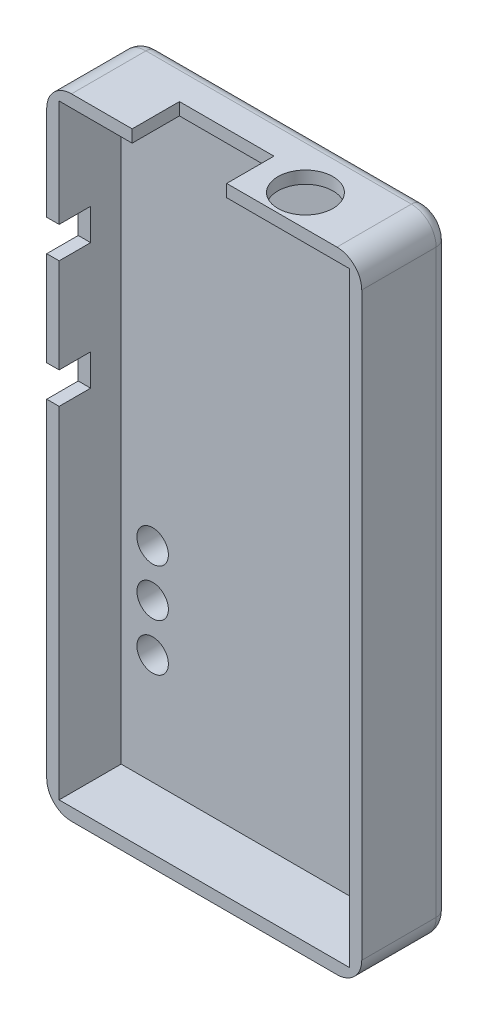
from build123d import *

# Parameters (mm, degrees)
SKETCH1_W           = 25.4
SKETCH1_H           = 50.8
BOSS_EXTRUDE1_DEPTH = 2.00000108
SKETCH2_W           = 25.4
SKETCH2_H           = 50.8
SKETCH2_W_2         = 23.39999892
SKETCH2_H_2         = 48.79999892
BOSS_EXTRUDE2_DEPTH = 4.999999906
FILLET1_R           = 2.000000064
FILLET2_R           = 1.000000032
CUT_EXTRUDE3_REACH  = 52.8
SKETCH6_R           = 2.2225
CUT_EXTRUDE4_REACH  = 52.8
SKETCH7_W           = 7.62
SKETCH7_H           = 3.81
CUT_EXTRUDE5_REACH  = 27.4
SKETCH8_W           = 2.54
SKETCH8_H           = 2.54
CUT_EXTRUDE6_REACH  = 9
SKETCH9_R           = 1.27


with BuildPart() as part:
    # Sketch1 → Boss-Extrude1 (new body)
    with BuildSketch(Plane.XY):
        with Locations((12.7, 25.4)):
            Rectangle(SKETCH1_W, SKETCH1_H)
    extrude(amount=BOSS_EXTRUDE1_DEPTH)

    # Sketch2 → Boss-Extrude2 (add)
    with BuildSketch(Plane.XY.offset(2.00000108)):
        with Locations((12.7, 25.4)):
            Rectangle(SKETCH2_W, SKETCH2_H)
        with Locations((12.7, 25.4)):
            Rectangle(SKETCH2_W_2, SKETCH2_H_2, mode=Mode.SUBTRACT)
    extrude(amount=BOSS_EXTRUDE2_DEPTH)

    # Fillet1
    fillet1_edges = [part.edges().sort_by_distance(p)[0] for p in [
        (0, 50.8, 3.500000493),
        (25.4, 50.8, 3.500000493),
        (25.4, 0, 3.500000493),
        (0, 0, 3.500000493),
    ]]
    fillet(fillet1_edges, radius=FILLET1_R)

    # Fillet2
    fillet2_edges = [part.edges().sort_by_distance(p)[0] for p in [
        (12.7, 0, 0),
        (0, 25.4, 0),
        (12.7, 50.8, 0),
        (25.4, 25.4, 0),
        (24.814213544, 50.214213544, 0),
        (0.585786456, 50.214213544, 0),
        (24.814213544, 0.585786456, 0),
        (0.585786456, 0.585786456, 0),
    ]]
    fillet(fillet2_edges, radius=FILLET2_R)

    # Sketch6 → Cut-Extrude3 (cut, up to next)
    with BuildSketch(Plane(origin=(0, 50.8, 0), x_dir=(1, 0, 0), z_dir=(0, 1, 0)), mode=Mode.PRIVATE) as cut_extrude3_sk1:
        with Locations((18.319999936, -4.460000986)):
            Circle(SKETCH6_R)
    cut_extrude3_tool1 = extrude(cut_extrude3_sk1.sketch, amount=-CUT_EXTRUDE3_REACH, mode=Mode.PRIVATE) & part.part
    add(cut_extrude3_tool1.solids().sort_by_distance((18.32, 50.8, 4.460001))[0], mode=Mode.SUBTRACT)

    # Sketch7 → Cut-Extrude4 (cut, up to next)
    with BuildSketch(Plane(origin=(0, 50.8, 0), x_dir=(1, 0, 0), z_dir=(0, 1, 0)), mode=Mode.PRIVATE) as cut_extrude4_sk1:
        with Locations((10.699999936, -5.095000986)):
            Rectangle(SKETCH7_W, SKETCH7_H)
    cut_extrude4_tool1 = extrude(cut_extrude4_sk1.sketch, amount=-CUT_EXTRUDE4_REACH, mode=Mode.PRIVATE) & part.part
    add(cut_extrude4_tool1.solids().sort_by_distance((10.7, 50.8, 5.095001))[0], mode=Mode.SUBTRACT)

    # Sketch8 → Cut-Extrude5 (cut, up to next)
    with BuildSketch(Plane.ZY, mode=Mode.PRIVATE) as cut_extrude5_sk1:
        with Locations((5.730000986, 39.909999936)):
            Rectangle(SKETCH8_W, SKETCH8_H)
    cut_extrude5_tool1 = extrude(cut_extrude5_sk1.sketch, amount=-CUT_EXTRUDE5_REACH, mode=Mode.PRIVATE) & part.part
    add(cut_extrude5_tool1.solids().sort_by_distance((0, 39.91, 5.730001))[0], mode=Mode.SUBTRACT)
    # Sketch8 → Cut-Extrude5 (cut, up to next)
    with BuildSketch(Plane.ZY, mode=Mode.PRIVATE) as cut_extrude5_sk2:
        with Locations((5.730000986, 29.749999936)):
            Rectangle(SKETCH8_W, SKETCH8_H)
    cut_extrude5_tool2 = extrude(cut_extrude5_sk2.sketch, amount=-CUT_EXTRUDE5_REACH, mode=Mode.PRIVATE) & part.part
    add(cut_extrude5_tool2.solids().sort_by_distance((0, 29.75, 5.730001))[0], mode=Mode.SUBTRACT)

    # Sketch9 → Cut-Extrude6 (cut, up to next)
    with BuildSketch(Plane(origin=(0, 0, 0), x_dir=(-1, 0, 0), z_dir=(0, 0, -1)), mode=Mode.PRIVATE) as cut_extrude6_sk1:
        with Locations((-3.540000032, 9.890000032)):
            Circle(SKETCH9_R)
    cut_extrude6_tool1 = extrude(cut_extrude6_sk1.sketch, amount=-CUT_EXTRUDE6_REACH, mode=Mode.PRIVATE) & part.part
    add(cut_extrude6_tool1.solids().sort_by_distance((3.54, 9.89, 0))[0], mode=Mode.SUBTRACT)
    # Sketch9 → Cut-Extrude6 (cut, up to next)
    with BuildSketch(Plane(origin=(0, 0, 0), x_dir=(-1, 0, 0), z_dir=(0, 0, -1)), mode=Mode.PRIVATE) as cut_extrude6_sk2:
        with Locations((-3.540000032, 13.700000032)):
            Circle(SKETCH9_R)
    cut_extrude6_tool2 = extrude(cut_extrude6_sk2.sketch, amount=-CUT_EXTRUDE6_REACH, mode=Mode.PRIVATE) & part.part
    add(cut_extrude6_tool2.solids().sort_by_distance((3.54, 13.7, 0))[0], mode=Mode.SUBTRACT)
    # Sketch9 → Cut-Extrude6 (cut, up to next)
    with BuildSketch(Plane(origin=(0, 0, 0), x_dir=(-1, 0, 0), z_dir=(0, 0, -1)), mode=Mode.PRIVATE) as cut_extrude6_sk3:
        with Locations((-3.540000032, 17.510000032)):
            Circle(SKETCH9_R)
    cut_extrude6_tool3 = extrude(cut_extrude6_sk3.sketch, amount=-CUT_EXTRUDE6_REACH, mode=Mode.PRIVATE) & part.part
    add(cut_extrude6_tool3.solids().sort_by_distance((3.54, 17.51, 0))[0], mode=Mode.SUBTRACT)


solid = part.part
